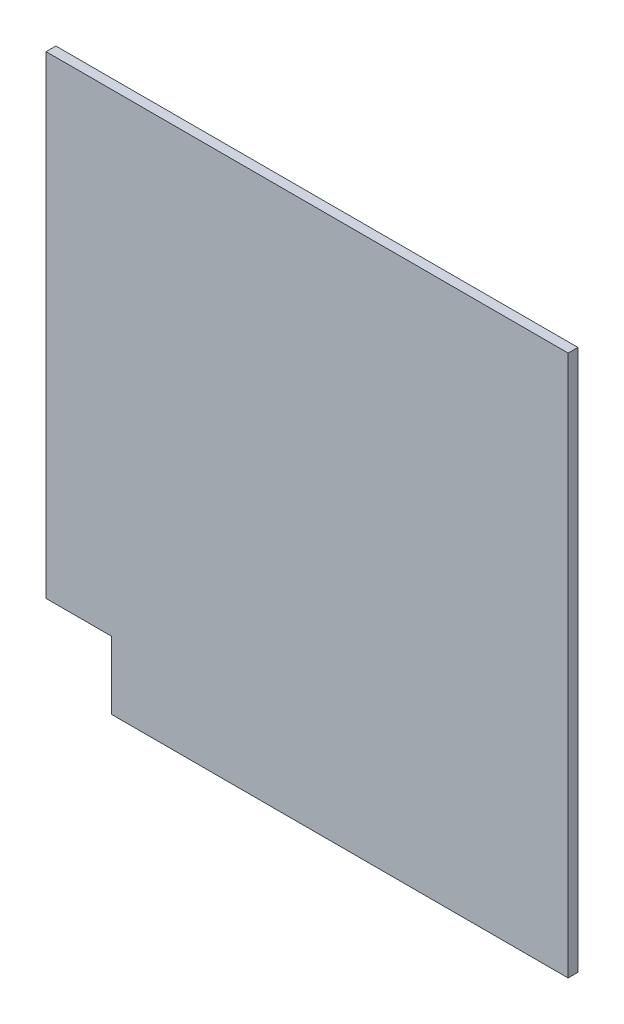
from build123d import *

# Parameters (mm, degrees)
BOSS_EXTRUDE1_DEPTH = 1.5


with BuildPart() as part:
    # Sketch1 → Boss-Extrude1 (new body)
    with BuildSketch(Plane.XY):
        Polygon((-40, 41.469286433), (40, 41.469286433), (40, -41.469286433), (-30, -41.469286433), (-30, -31.101964825), (-40, -31.101964825), align=None)
    extrude(amount=BOSS_EXTRUDE1_DEPTH)


solid = part.part
